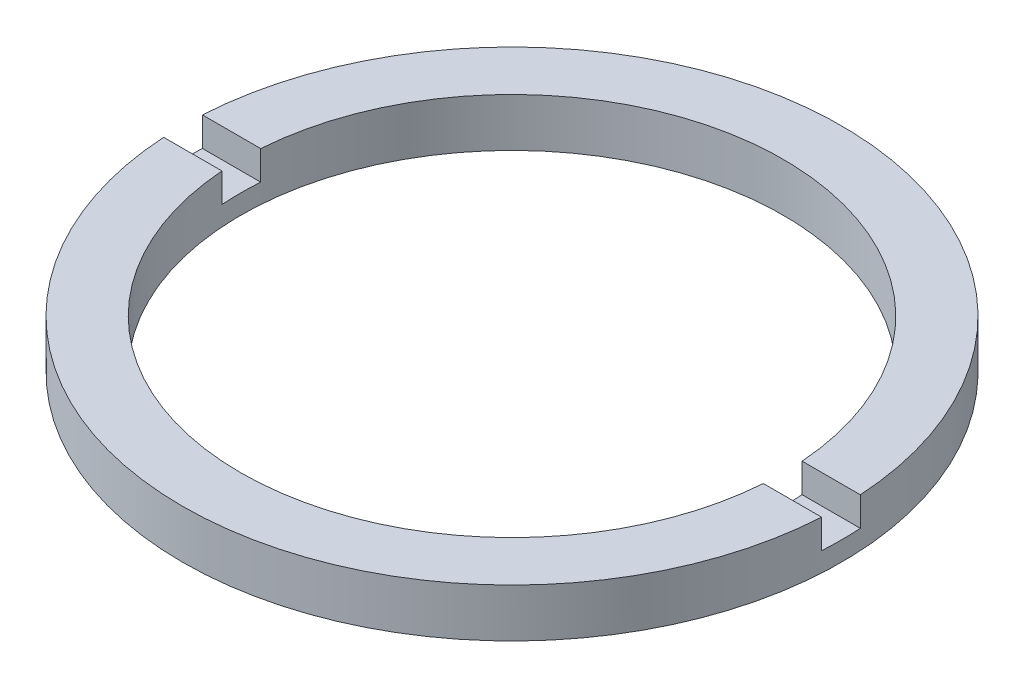
from build123d import *

# Parameters (mm, degrees)
SKETCH_1_W          = 3
SKETCH_1_H          = 2.5
SKETCH_2_W          = 53.705080546
SKETCH_2_H          = 2
CUT_EXTRUDE_1_DEPTH = 1.5


with BuildPart() as part:
    # 草图1 → 旋转1 (revolve)
    with BuildSketch(Plane.XY, mode=Mode.PRIVATE) as revolve_1_sk:
        with Locations((15.5, -3.214249787)):
            Rectangle(SKETCH_1_W, SKETCH_1_H)
    revolve(revolve_1_sk.sketch.rotate(Axis((0, 56.260842627, 0), (0, -1, 0)), 90), axis=Axis((0, 56.260842627, 0), (0, -1, 0)))  # turned: the seam where the file's is

    # 草图2 → 切除-拉伸1 (cut)
    with BuildSketch(Plane(origin=(0, -1.964249787, 0), x_dir=(1, 0, 0), z_dir=(0, 1, 0))):
        Rectangle(SKETCH_2_W, SKETCH_2_H)
    extrude(amount=-CUT_EXTRUDE_1_DEPTH, mode=Mode.SUBTRACT)


solid = part.part
